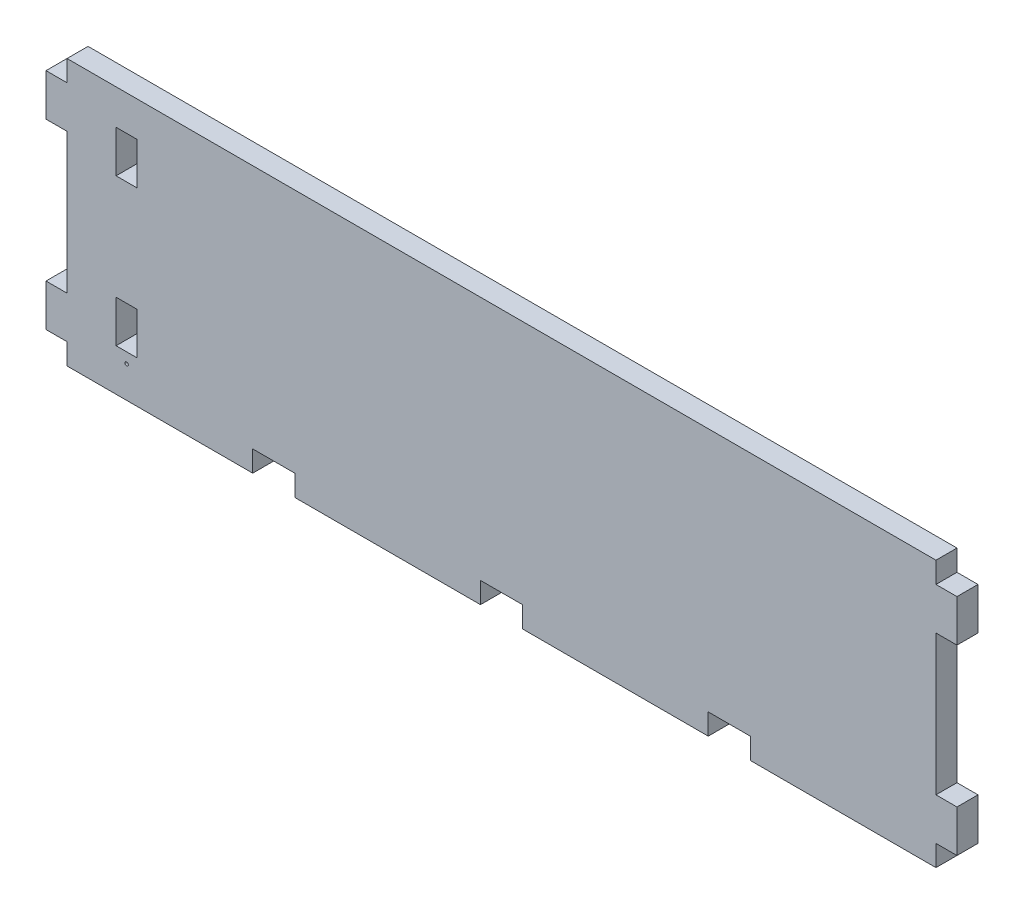
from build123d import *

# Parameters (mm, degrees)
SKETCH1_W           = 6
SKETCH1_H           = 12
BOSS_EXTRUDE1_DEPTH = 6
SKETCH3_R           = 0.5
CUT_EXTRUDE1_DEPTH  = 7


with BuildPart() as part:
    # Sketch1 → Boss-Extrude1 (new body)
    with BuildSketch(Plane.XY):
        Polygon((-124, 38), (-124, 32), (-124, 20), (-124, -20), (-124, -32), (-124, -38), (-71, -38), (-71, -32), (-59, -32), (-59, -38), (-6, -38), (-6, -32), (6, -32), (6, -38), (59, -38), (59, -32), (71, -32), (71, -38), (124, -38), (124, -32), (124, -20), (124, 20), (124, 32), (124, 38), align=None)
        with Locations((-107, -20)):
            Rectangle(SKETCH1_W, SKETCH1_H, mode=Mode.SUBTRACT)
        with Locations((-107, 22)):
            Rectangle(SKETCH1_W, SKETCH1_H, mode=Mode.SUBTRACT)
        with Locations((-127, -26)):
            Rectangle(SKETCH1_W, SKETCH1_H)
        with Locations((-127, 26)):
            Rectangle(SKETCH1_W, SKETCH1_H)
        with Locations((127, 26)):
            Rectangle(SKETCH1_W, SKETCH1_H)
        with Locations((127, -26)):
            Rectangle(SKETCH1_W, SKETCH1_H)
    extrude(amount=-BOSS_EXTRUDE1_DEPTH)

    # Sketch3 → Cut-Extrude1 (cut, through all)
    with BuildSketch(Plane.XY):
        with Locations((-107, -29)):
            Circle(SKETCH3_R)
    extrude(amount=-CUT_EXTRUDE1_DEPTH, mode=Mode.SUBTRACT)


solid = part.part
